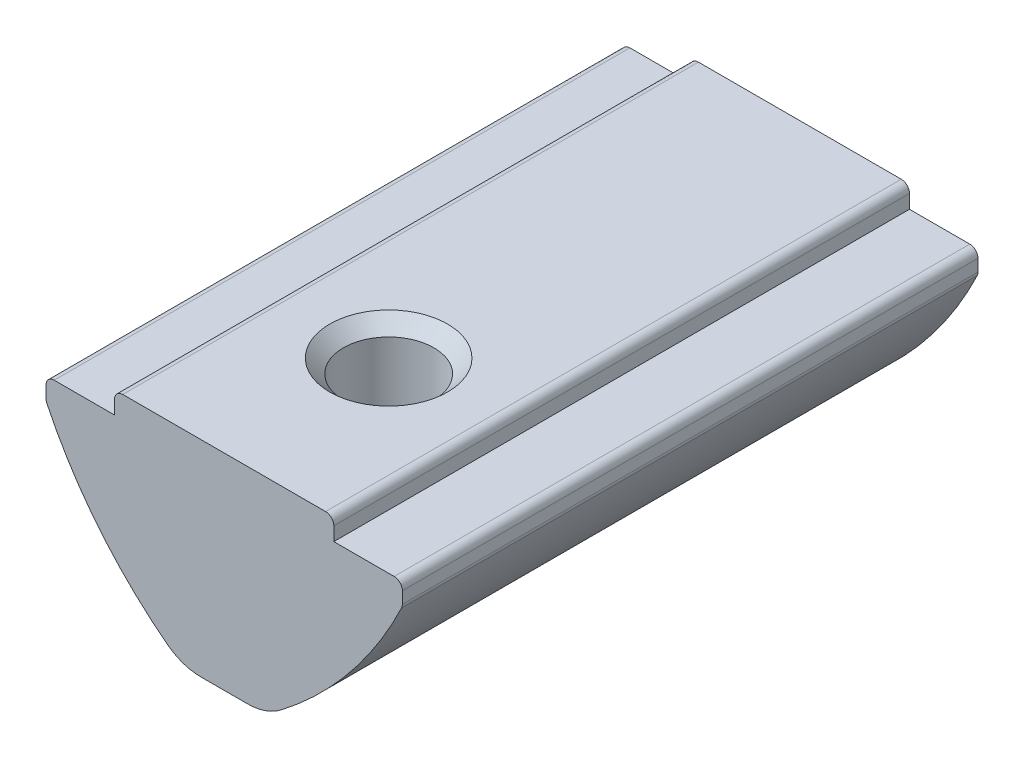
from build123d import *

# Parameters (mm, degrees)
EXTRUDE_1_DEPTH             = 10.5
FILLET_1_R                  = 0.3
FILLET_2_R                  = 2
HOLE_WIZARD_M41_D           = 3.3
HOLE_WIZARD_M41_CSINK_D     = 4.3
HOLE_WIZARD_M41_CSINK_ANGLE = 90


with BuildPart() as part:
    # Эскиз1 → Бобышка-Вытянуть1 (new body, symmetric)
    with BuildSketch(Plane.XY):
        with BuildLine():
            Line((-4, 0), (4, 0))
            Line((4, 0), (4, -0.8))
            Line((4, -0.8), (6.5, -0.8))
            Line((6.5, -0.8), (6.5, -1.6))
            ThreePointArc((6.5, -1.6), (4.386776199, -4.87777644), (1.5, -7.5))
            Line((1.5, -7.5), (-1.5, -7.5))
            ThreePointArc((-1.5, -7.5), (-4.386776199, -4.87777644), (-6.5, -1.6))
            Line((-6.5, -1.6), (-6.5, -0.8))
            Line((-6.5, -0.8), (-4, -0.8))
            Line((-4, -0.8), (-4, 0))
        make_face()
    extrude(amount=EXTRUDE_1_DEPTH, both=True)

    # Скругление1
    fillet_1_edges = [part.edges().sort_by_distance(p)[0] for p in [
        (6.5, -0.8, 0),
        (6.5, -1.6, 0),
        (-6.5, -1.6, 0),
        (-6.5, -0.8, 0),
        (-4, 0, 0),
        (4, 0, 0),
    ]]
    fillet(fillet_1_edges, radius=FILLET_1_R)

    # Скругление2
    fillet_2_edges = [part.edges().sort_by_distance(p)[0] for p in [
        (1.5, -7.5, 0),
        (-1.5, -7.5, 0),
    ]]
    fillet(fillet_2_edges, radius=FILLET_2_R)

    # Отверстие обработанное метчиком M41 (through all)
    with Locations(Plane(origin=(0, 0, 0), x_dir=(1, 0, 0), z_dir=(0, 1, 0))):
        with Locations((0, -4.5)):
            CounterSinkHole(HOLE_WIZARD_M41_D / 2, HOLE_WIZARD_M41_CSINK_D / 2, counter_sink_angle=HOLE_WIZARD_M41_CSINK_ANGLE)

    # Эскиз5 → Повернуть1 (revolve)
    with BuildSketch(Plane(origin=(0, 0, 0), x_dir=(0, 0, -1), z_dir=(1, 0, 0))):
        with BuildLine():
            Line((6.5, -4.3), (6.5, -8.3))
            ThreePointArc((6.5, -8.3), (4.5, -6.3), (6.5, -4.3))
        make_face()
    revolve(axis=Axis((0, -4.3, -6.5), (0, -1, 0)))


solid = part.part
